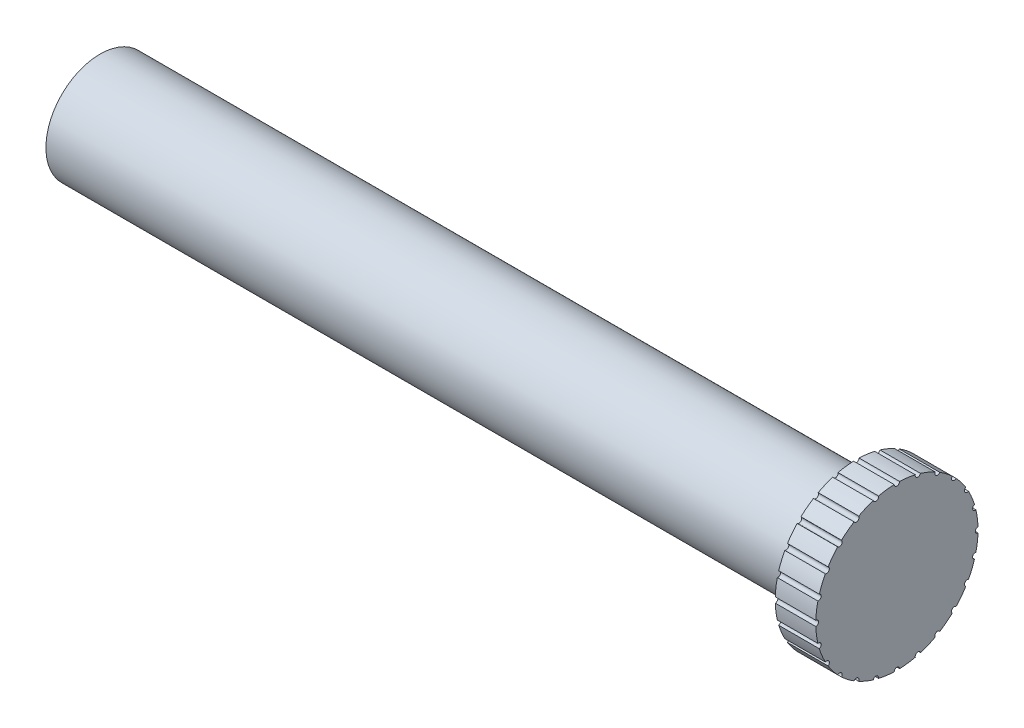
from build123d import *

# Parameters (mm, degrees)
SKETCH1_R           = 4
BOSS_EXTRUDE1_DEPTH = 55.94
SKETCH2_R           = 6
BOSS_EXTRUDE2_DEPTH = 3
SKETCH3_R           = 0.2
CUT_EXTRUDE1_DEPTH  = 3
CIRPATTERN1_COUNT   = 24


with BuildPart() as part:
    # Sketch1 → Boss-Extrude1 (new body)
    with BuildSketch(Plane(origin=(0, 0, 0), x_dir=(0, 0, -1), z_dir=(1, 0, 0))):
        Circle(SKETCH1_R)
    extrude(amount=BOSS_EXTRUDE1_DEPTH)

    # Sketch2 → Boss-Extrude2 (add)
    with BuildSketch(Plane(origin=(55.94, 0, 0), x_dir=(0, 0, -1), z_dir=(1, 0, 0))):
        Circle(SKETCH2_R)
    extrude(amount=BOSS_EXTRUDE2_DEPTH)

    # Sketch3 → Cut-Extrude1 (cut)
    with BuildSketch(Plane(origin=(58.94, 0, 0), x_dir=(0, 0, -1), z_dir=(1, 0, 0))):
        with Locations((-6, 0)):
            Circle(SKETCH3_R)
    cut_extrude1 = extrude(amount=-CUT_EXTRUDE1_DEPTH, mode=Mode.SUBTRACT)

    # CirPattern1: Cut-Extrude1 ×24 about axis
    cirpattern1_axis = Axis((0, 0, 0), (1, 0, 0))
    for i in range(1, CIRPATTERN1_COUNT):
        add(cut_extrude1.rotate(cirpattern1_axis, i * 360 / CIRPATTERN1_COUNT), mode=Mode.SUBTRACT)


solid = part.part
